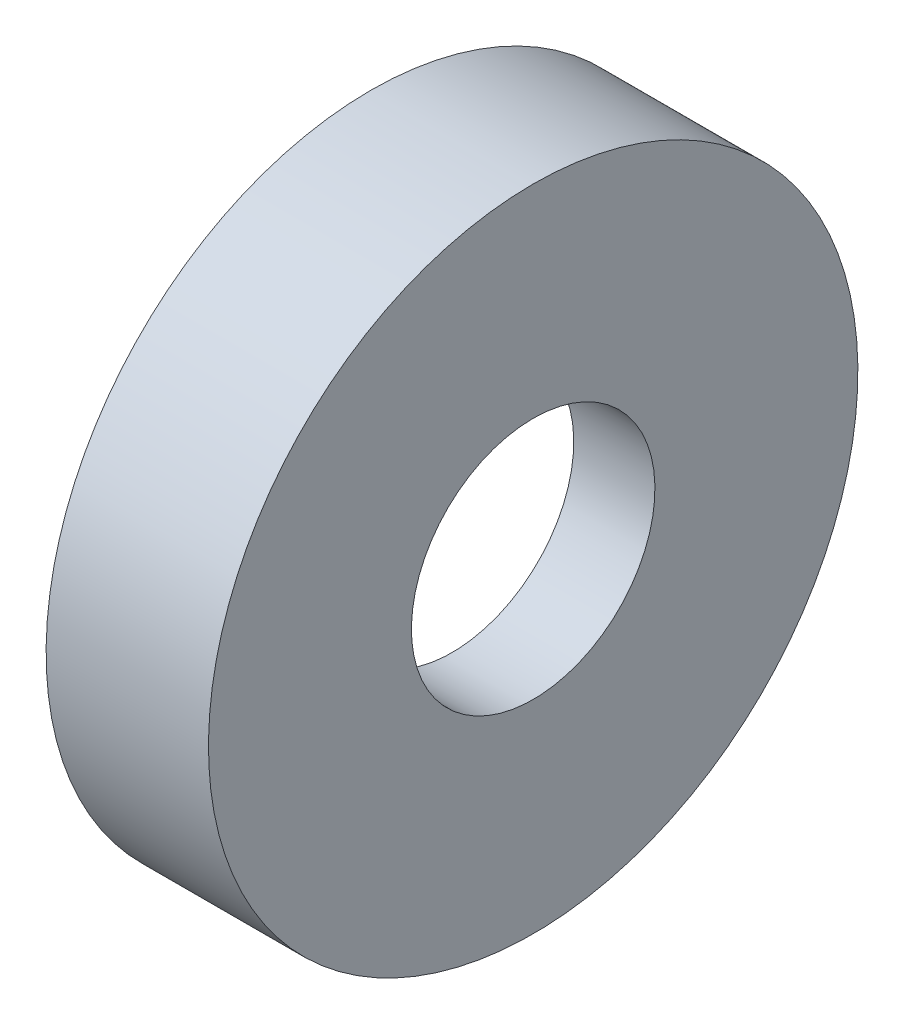
from build123d import *


with BuildPart() as part:
    # Sketch1 → Revolve1 (revolve)
    with BuildSketch(Plane.XY):
        Polygon((-3.175, 12.7), (3.175, 12.7), (3.175, 4.7625), (0, 4.7625), (0, 11.1125), (-3.175, 11.1125), align=None)
    revolve(axis=Axis((3.175, 0, 0), (-1, 0, 0)))


solid = part.part
